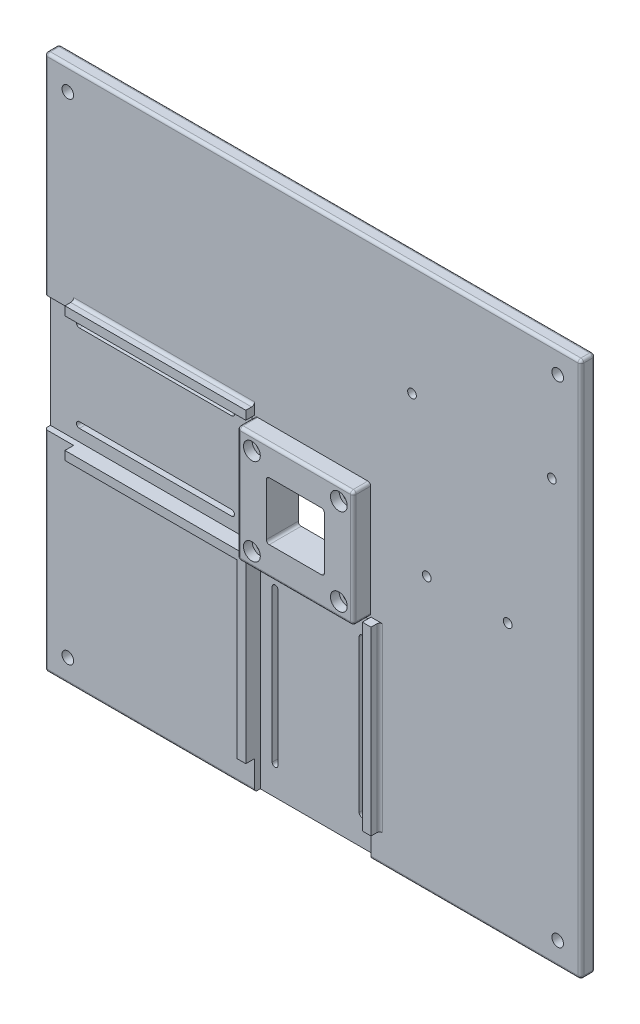
from build123d import *

# Parameters (mm, degrees)
ESQUISSE1_W                  = 185
ESQUISSE1_H                  = 185
BOSS_EXTRU_1_DEPTH           = 5
CONG_1_R                     = 1
ENL_V_MAT_EXTRU_4_REACH      = 7
ESQUISSE9_R                  = 2
ESQUISSE4_R                  = 1.5
ESQUISSE4_W                  = 20
ESQUISSE4_H                  = 20
ENL_V_MAT_EXTRU_5_DEPTH      = 1
ENL_V_MAT_EXTRU_5_DEPTH_BACK = 6
ESQUISSE11_W                 = 40
ESQUISSE11_H                 = 40
BOSS_EXTRU_3_DEPTH           = 6
CONG_2_R                     = 1
ESQUISSE12_R                 = 1.5
ENL_V_MAT_EXTRU_6_DEPTH      = 12
ESQUISSE13_R                 = 2.9
ENL_V_MAT_EXTRU_7_DEPTH      = 3
ENL_V_MAT_EXTRU_8_DEPTH      = 6
ESQUISSE15_W                 = 62.4
ESQUISSE15_H                 = 3
ESQUISSE15_W_2               = 3
ESQUISSE15_H_2               = 62.4
BOSS_EXTRU_4_DEPTH           = 3
CONG_3_R                     = 1
ESQUISSE20_R                 = 1.5
ENL_V_MAT_EXTRU_12_DEPTH     = 10
ESQUISSE21_W                 = 74.715624907
ESQUISSE21_H                 = 40.2
ENL_V_MAT_EXTRU_13_DEPTH     = 2
ESQUISSE22_W                 = 40.2
ESQUISSE22_H                 = 79.103769468
ENL_V_MAT_EXTRU_20_DEPTH     = 2


with BuildPart() as part:
    # Esquisse1 → Boss.-Extru.1 (new body)
    with BuildSketch(Plane.XY):
        Rectangle(ESQUISSE1_W, ESQUISSE1_H)
    extrude(amount=BOSS_EXTRU_1_DEPTH)

    # Congé1
    cong_1_edges = [part.edges().sort_by_distance(p)[0] for p in [
        (92.5, 0, 5),
        (0, 92.5, 5),
        (-92.5, 0, 5),
        (0, 92.5, 0),
        (92.5, 0, 0),
        (0, -92.5, 0),
        (-92.5, 0, 0),
        (-92.5, 92.5, 2.5),
        (92.5, 92.5, 2.5),
        (92.5, -92.5, 2.5),
        (-92.5, -92.5, 2.5),
        (0, -92.5, 5),
    ]]
    fillet(cong_1_edges, radius=CONG_1_R)

    # Esquisse9 → Enlèv. mat.-Extru.4 (cut, up to next)
    with BuildSketch(Plane(origin=(0, 0, 0), x_dir=(-1, 0, 0), z_dir=(0, 0, -1)), mode=Mode.PRIVATE) as enl_v_mat_extru_4_sk1:
        with Locations((-84.5, 84.5)):
            Circle(ESQUISSE9_R)
    enl_v_mat_extru_4_tool1 = extrude(enl_v_mat_extru_4_sk1.sketch, amount=-ENL_V_MAT_EXTRU_4_REACH, mode=Mode.PRIVATE) & part.part
    add(enl_v_mat_extru_4_tool1.solids().sort_by_distance((84.5, 84.5, 0))[0], mode=Mode.SUBTRACT)
    # Esquisse9 → Enlèv. mat.-Extru.4 (cut, up to next)
    with BuildSketch(Plane(origin=(0, 0, 0), x_dir=(-1, 0, 0), z_dir=(0, 0, -1)), mode=Mode.PRIVATE) as enl_v_mat_extru_4_sk2:
        with Locations((84.5, 84.5)):
            Circle(ESQUISSE9_R)
    enl_v_mat_extru_4_tool2 = extrude(enl_v_mat_extru_4_sk2.sketch, amount=-ENL_V_MAT_EXTRU_4_REACH, mode=Mode.PRIVATE) & part.part
    add(enl_v_mat_extru_4_tool2.solids().sort_by_distance((-84.5, 84.5, 0))[0], mode=Mode.SUBTRACT)
    # Esquisse9 → Enlèv. mat.-Extru.4 (cut, up to next)
    with BuildSketch(Plane(origin=(0, 0, 0), x_dir=(-1, 0, 0), z_dir=(0, 0, -1)), mode=Mode.PRIVATE) as enl_v_mat_extru_4_sk3:
        with Locations((84.5, -84.5)):
            Circle(ESQUISSE9_R)
    enl_v_mat_extru_4_tool3 = extrude(enl_v_mat_extru_4_sk3.sketch, amount=-ENL_V_MAT_EXTRU_4_REACH, mode=Mode.PRIVATE) & part.part
    add(enl_v_mat_extru_4_tool3.solids().sort_by_distance((-84.5, -84.5, 0))[0], mode=Mode.SUBTRACT)
    # Esquisse9 → Enlèv. mat.-Extru.4 (cut, up to next)
    with BuildSketch(Plane(origin=(0, 0, 0), x_dir=(-1, 0, 0), z_dir=(0, 0, -1)), mode=Mode.PRIVATE) as enl_v_mat_extru_4_sk4:
        with Locations((-84.5, -84.5)):
            Circle(ESQUISSE9_R)
    enl_v_mat_extru_4_tool4 = extrude(enl_v_mat_extru_4_sk4.sketch, amount=-ENL_V_MAT_EXTRU_4_REACH, mode=Mode.PRIVATE) & part.part
    add(enl_v_mat_extru_4_tool4.solids().sort_by_distance((84.5, -84.5, 0))[0], mode=Mode.SUBTRACT)

    # Esquisse4 → Enlèv. mat.-Extru.5 (cut, two sides)
    with BuildSketch(Plane.XY.offset(5)) as enl_v_mat_extru_5_sk:
        with Locations((-15, 15)):
            Circle(ESQUISSE4_R)
        with Locations((15, 15)):
            Circle(ESQUISSE4_R)
        with Locations((15, -15)):
            Circle(ESQUISSE4_R)
        with Locations((-15, -15)):
            Circle(ESQUISSE4_R)
        Rectangle(ESQUISSE4_W, ESQUISSE4_H)
    extrude(amount=ENL_V_MAT_EXTRU_5_DEPTH, mode=Mode.SUBTRACT)
    extrude(enl_v_mat_extru_5_sk.sketch, amount=-ENL_V_MAT_EXTRU_5_DEPTH_BACK, mode=Mode.SUBTRACT)

    # Esquisse11 → Boss.-Extru.3 (add)
    with BuildSketch(Plane.XY.offset(5)):
        Rectangle(ESQUISSE11_W, ESQUISSE11_H)
    extrude(amount=BOSS_EXTRU_3_DEPTH)

    # Congé2
    cong_2_edges = [part.edges().sort_by_distance(p)[0] for p in [
        (-20, -20, 8),
        (20, -20, 8),
        (0, 20, 11),
        (20, 20, 8),
        (-20, 0, 11),
        (-20, 20, 8),
        (0, -20, 11),
        (20, 0, 11),
        (-10, -10, 2.5),
        (-10, 10, 2.5),
        (10, 10, 2.5),
        (10, -10, 2.5),
    ]]
    fillet(cong_2_edges, radius=CONG_2_R)

    # Esquisse12 → Enlèv. mat.-Extru.6 (cut, through all)
    with BuildSketch(Plane.XY.offset(11)):
        with BuildLine():
            Line((10, -9), (10, 9))
            ThreePointArc((10, 9), (9.707106781, 9.707106781), (9, 10))
            Line((9, 10), (-9, 10))
            ThreePointArc((-9, 10), (-9.707106781, 9.707106781), (-10, 9))
            Line((-10, 9), (-10, -9))
            ThreePointArc((-10, -9), (-9.707106781, -9.707106781), (-9, -10))
            Line((-9, -10), (9, -10))
            ThreePointArc((9, -10), (9.707106781, -9.707106781), (10, -9))
        make_face()
        with Locations((15, 15)):
            Circle(ESQUISSE12_R)
        with Locations((-15, 15)):
            Circle(ESQUISSE12_R)
        with Locations((15, -15)):
            Circle(ESQUISSE12_R)
        with Locations((-15, -15)):
            Circle(ESQUISSE12_R)
    extrude(amount=-ENL_V_MAT_EXTRU_6_DEPTH, mode=Mode.SUBTRACT)

    # Esquisse13 → Enlèv. mat.-Extru.7 (cut)
    with BuildSketch(Plane.XY.offset(11)):
        with Locations((-15, 15)):
            Circle(ESQUISSE13_R)
        with Locations((15, 15)):
            Circle(ESQUISSE13_R)
        with Locations((15, -15)):
            Circle(ESQUISSE13_R)
        with Locations((-15, -15)):
            Circle(ESQUISSE13_R)
    extrude(amount=-ENL_V_MAT_EXTRU_7_DEPTH, mode=Mode.SUBTRACT)

    # Esquisse14 → Enlèv. mat.-Extru.8 (cut, through all)
    with BuildSketch(Plane.XY.offset(5)):
        with BuildLine():
            Line((-82.5, 16), (-30, 16))
            ThreePointArc((-30, 16), (-29, 15), (-30, 14))
            Line((-30, 14), (-82.5, 14))
            ThreePointArc((-82.5, 14), (-83.5, 15), (-82.5, 16))
        make_face()
        with BuildLine():
            Line((-30, -16), (-82.5, -16))
            ThreePointArc((-82.5, -16), (-83.5, -15), (-82.5, -14))
            Line((-82.5, -14), (-30, -14))
            ThreePointArc((-30, -14), (-29, -15), (-30, -16))
        make_face()
        with BuildLine():
            Line((16, -30), (16, -82.5))
            ThreePointArc((16, -82.5), (15, -83.5), (14, -82.5))
            Line((14, -82.5), (14, -30))
            ThreePointArc((14, -30), (15, -29), (16, -30))
        make_face()
        with BuildLine():
            Line((-16, -82.5), (-16, -30))
            ThreePointArc((-16, -30), (-15, -29), (-14, -30))
            Line((-14, -30), (-14, -82.5))
            ThreePointArc((-14, -82.5), (-15, -83.5), (-16, -82.5))
        make_face()
    extrude(amount=-ENL_V_MAT_EXTRU_8_DEPTH, mode=Mode.SUBTRACT)

    # Esquisse15 → Boss.-Extru.4 (add)
    with BuildSketch(Plane.XY.offset(5)):
        Polygon((-20.1, -20.1), (-20.1, -82.5), (-23.1, -82.5), (-23.1, -23.1), (-82.5, -23.1), (-82.5, -20.1), align=None)
        with Locations((-51.3, 21.6)):
            Rectangle(ESQUISSE15_W, ESQUISSE15_H)
        with Locations((21.6, -51.3)):
            Rectangle(ESQUISSE15_W_2, ESQUISSE15_H_2)
    extrude(amount=BOSS_EXTRU_4_DEPTH)

    # Congé3
    cong_3_edges = [part.edges().sort_by_distance(p)[0] for p in [
        (-51.3, 23.1, 5),
        (-52.8, -23.1, 5),
        (-23.1, -52.8, 5),
        (23.1, -51.3, 5),
    ]]
    fillet(cong_3_edges, radius=CONG_3_R)

    # Esquisse20 → Enlèv. mat.-Extru.12 (cut)
    with BuildSketch(Plane.XY.offset(5)):
        with Locations((39.32, 1.7)):
            Circle(ESQUISSE20_R)
        with Locations((34.24, 53.77)):
            Circle(ESQUISSE20_R)
        with Locations((82.5, 52.5)):
            Circle(ESQUISSE20_R)
        with Locations((67.26, 1.7)):
            Circle(ESQUISSE20_R)
    extrude(amount=-ENL_V_MAT_EXTRU_12_DEPTH, mode=Mode.SUBTRACT)

    # Esquisse21 → Enlèv. mat.-Extru.13 (cut)
    with BuildSketch(Plane.XY.offset(5)):
        with Locations((-58.357812454, 0)):
            Rectangle(ESQUISSE21_W, ESQUISSE21_H)
    extrude(amount=-ENL_V_MAT_EXTRU_13_DEPTH, mode=Mode.SUBTRACT)

    # Esquisse22 → Enlèv. mat.-Extru.20 (cut)
    with BuildSketch(Plane.XY.offset(5)):
        with Locations((0, -60.651884734)):
            Rectangle(ESQUISSE22_W, ESQUISSE22_H)
    extrude(amount=-ENL_V_MAT_EXTRU_20_DEPTH, mode=Mode.SUBTRACT)


solid = part.part
